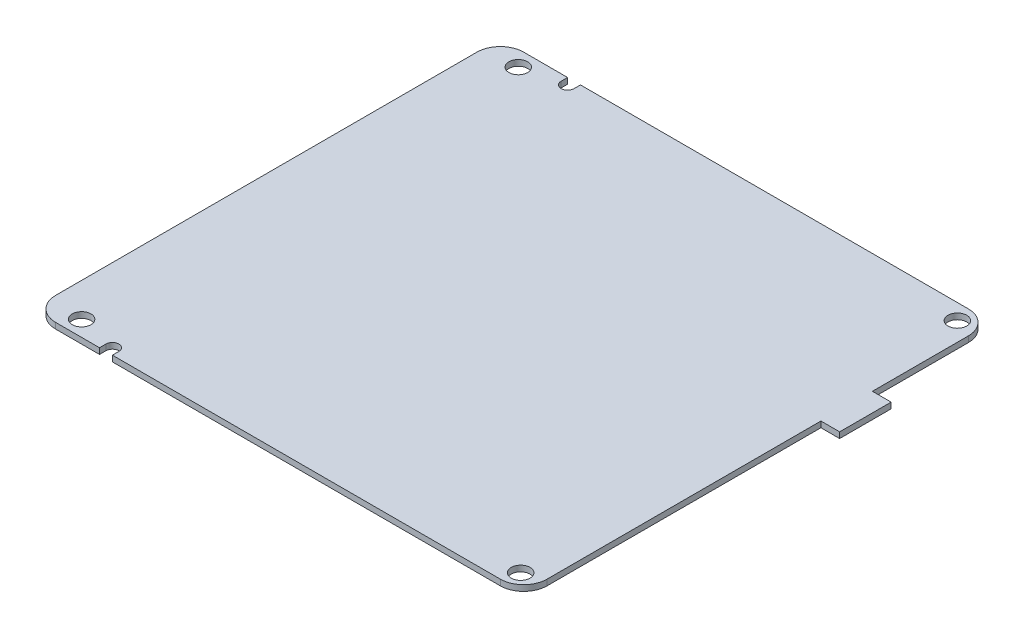
from build123d import *

# Parameters (mm, degrees)
SKETCH1_W                  = 105
SKETCH1_H                  = 100
SKETCH1_W_2                = 4
SKETCH1_H_2                = 11
MAIN_PCB_DEPTH             = 1.25
MAIN_PCB_ROUNDED_CORNERS_R = 5
MAIN_PCB_HOLES_REACH       = 3.25
SKETCH2_R                  = 2
SKETCH2_R_2                = 1.375


with BuildPart() as part:
    # Sketch1 → Main PCB (new body)
    with BuildSketch(Plane(origin=(0, 0, 0), x_dir=(1, 0, 0), z_dir=(0, 1, 0))):
        Rectangle(SKETCH1_W, SKETCH1_H)
        with Locations((54.5, 19)):
            Rectangle(SKETCH1_W_2, SKETCH1_H_2)
    extrude(amount=MAIN_PCB_DEPTH)

    # Main PCB rounded corners
    main_pcb_rounded_corners_edges = [part.edges().sort_by_distance(p)[0] for p in [
        (52.5, 0.625, 50),
        (-52.5, 0.625, 50),
        (-52.5, 0.625, -50),
        (52.5, 0.625, -50),
    ]]
    fillet(main_pcb_rounded_corners_edges, radius=MAIN_PCB_ROUNDED_CORNERS_R)

    # Sketch2 → Main PCB holes (cut, up to next)
    with BuildSketch(Plane(origin=(0, 1.25, 0), x_dir=(1, 0, 0), z_dir=(0, 1, 0)), mode=Mode.PRIVATE) as main_pcb_holes_sk1:
        with Locations((-45.3, 46.65)):
            Circle(SKETCH2_R)
    main_pcb_holes_tool1 = extrude(main_pcb_holes_sk1.sketch, amount=-MAIN_PCB_HOLES_REACH, mode=Mode.PRIVATE) & part.part
    add(main_pcb_holes_tool1.solids().sort_by_distance((-45.3, 1.25, -46.65))[0], mode=Mode.SUBTRACT)
    # Sketch2 → Main PCB holes (cut, up to next)
    with BuildSketch(Plane(origin=(0, 1.25, 0), x_dir=(1, 0, 0), z_dir=(0, 1, 0)), mode=Mode.PRIVATE) as main_pcb_holes_sk2:
        with Locations((48.5, 46.65)):
            Circle(SKETCH2_R)
    main_pcb_holes_tool2 = extrude(main_pcb_holes_sk2.sketch, amount=-MAIN_PCB_HOLES_REACH, mode=Mode.PRIVATE) & part.part
    add(main_pcb_holes_tool2.solids().sort_by_distance((48.5, 1.25, -46.65))[0], mode=Mode.SUBTRACT)
    # Sketch2 → Main PCB holes (cut, up to next)
    with BuildSketch(Plane(origin=(0, 1.25, 0), x_dir=(1, 0, 0), z_dir=(0, 1, 0)), mode=Mode.PRIVATE) as main_pcb_holes_sk3:
        with Locations((48.5, -46.65)):
            Circle(SKETCH2_R)
    main_pcb_holes_tool3 = extrude(main_pcb_holes_sk3.sketch, amount=-MAIN_PCB_HOLES_REACH, mode=Mode.PRIVATE) & part.part
    add(main_pcb_holes_tool3.solids().sort_by_distance((48.5, 1.25, 46.65))[0], mode=Mode.SUBTRACT)
    # Sketch2 → Main PCB holes (cut, up to next)
    with BuildSketch(Plane(origin=(0, 1.25, 0), x_dir=(1, 0, 0), z_dir=(0, 1, 0)), mode=Mode.PRIVATE) as main_pcb_holes_sk4:
        with Locations((-45.3, -46.65)):
            Circle(SKETCH2_R)
    main_pcb_holes_tool4 = extrude(main_pcb_holes_sk4.sketch, amount=-MAIN_PCB_HOLES_REACH, mode=Mode.PRIVATE) & part.part
    add(main_pcb_holes_tool4.solids().sort_by_distance((-45.3, 1.25, 46.65))[0], mode=Mode.SUBTRACT)
    # Sketch2 → Main PCB holes (cut, up to next)
    with BuildSketch(Plane(origin=(0, 1.25, 0), x_dir=(1, 0, 0), z_dir=(0, 1, 0)), mode=Mode.PRIVATE) as main_pcb_holes_sk5:
        with Locations((-36.75, -48.625)):
            Circle(SKETCH2_R_2)
    main_pcb_holes_tool5 = extrude(main_pcb_holes_sk5.sketch, amount=-MAIN_PCB_HOLES_REACH, mode=Mode.PRIVATE) & part.part
    add(main_pcb_holes_tool5.solids().sort_by_distance((-36.75, 1.25, 48.625))[0], mode=Mode.SUBTRACT)
    # Sketch2 → Main PCB holes (cut, up to next)
    with BuildSketch(Plane(origin=(0, 1.25, 0), x_dir=(1, 0, 0), z_dir=(0, 1, 0)), mode=Mode.PRIVATE) as main_pcb_holes_sk6:
        with BuildLine():
            ThreePointArc((-36.75, -50), (-37.722271824, -49.597271824), (-38.125, -48.625))
            Line((-38.125, -48.625), (-38.125, -50))
            Line((-38.125, -50), (-36.75, -50))
        make_face()
    main_pcb_holes_tool6 = extrude(main_pcb_holes_sk6.sketch, amount=-MAIN_PCB_HOLES_REACH, mode=Mode.PRIVATE) & part.part
    add(main_pcb_holes_tool6.solids().sort_by_distance((-37.817869, 1.25, 49.692869))[0], mode=Mode.SUBTRACT)
    # Sketch2 → Main PCB holes (cut, up to next)
    with BuildSketch(Plane(origin=(0, 1.25, 0), x_dir=(1, 0, 0), z_dir=(0, 1, 0)), mode=Mode.PRIVATE) as main_pcb_holes_sk7:
        with BuildLine():
            Line((-35.375, -50), (-35.375, -48.625))
            ThreePointArc((-35.375, -48.625), (-35.777728176, -49.597271824), (-36.75, -50))
            Line((-36.75, -50), (-35.375, -50))
        make_face()
    main_pcb_holes_tool7 = extrude(main_pcb_holes_sk7.sketch, amount=-MAIN_PCB_HOLES_REACH, mode=Mode.PRIVATE) & part.part
    add(main_pcb_holes_tool7.solids().sort_by_distance((-35.682131, 1.25, 49.692869))[0], mode=Mode.SUBTRACT)
    # Sketch2 → Main PCB holes (cut, up to next)
    with BuildSketch(Plane(origin=(0, 1.25, 0), x_dir=(1, 0, 0), z_dir=(0, 1, 0)), mode=Mode.PRIVATE) as main_pcb_holes_sk8:
        with BuildLine():
            Line((-36.75, 50), (-38.125, 50))
            Line((-38.125, 50), (-38.125, 48.625))
            ThreePointArc((-38.125, 48.625), (-37.722271824, 49.597271824), (-36.75, 50))
        make_face()
    main_pcb_holes_tool8 = extrude(main_pcb_holes_sk8.sketch, amount=-MAIN_PCB_HOLES_REACH, mode=Mode.PRIVATE) & part.part
    add(main_pcb_holes_tool8.solids().sort_by_distance((-37.817869, 1.25, -49.692869))[0], mode=Mode.SUBTRACT)
    # Sketch2 → Main PCB holes (cut, up to next)
    with BuildSketch(Plane(origin=(0, 1.25, 0), x_dir=(1, 0, 0), z_dir=(0, 1, 0)), mode=Mode.PRIVATE) as main_pcb_holes_sk9:
        with Locations((-36.75, 48.625)):
            Circle(SKETCH2_R_2)
    main_pcb_holes_tool9 = extrude(main_pcb_holes_sk9.sketch, amount=-MAIN_PCB_HOLES_REACH, mode=Mode.PRIVATE) & part.part
    add(main_pcb_holes_tool9.solids().sort_by_distance((-36.75, 1.25, -48.625))[0], mode=Mode.SUBTRACT)
    # Sketch2 → Main PCB holes (cut, up to next)
    with BuildSketch(Plane(origin=(0, 1.25, 0), x_dir=(1, 0, 0), z_dir=(0, 1, 0)), mode=Mode.PRIVATE) as main_pcb_holes_sk10:
        with BuildLine():
            Line((-35.375, 50), (-36.75, 50))
            ThreePointArc((-36.75, 50), (-35.777728176, 49.597271824), (-35.375, 48.625))
            Line((-35.375, 48.625), (-35.375, 50))
        make_face()
    main_pcb_holes_tool10 = extrude(main_pcb_holes_sk10.sketch, amount=-MAIN_PCB_HOLES_REACH, mode=Mode.PRIVATE) & part.part
    add(main_pcb_holes_tool10.solids().sort_by_distance((-35.682131, 1.25, -49.692869))[0], mode=Mode.SUBTRACT)


solid = part.part
